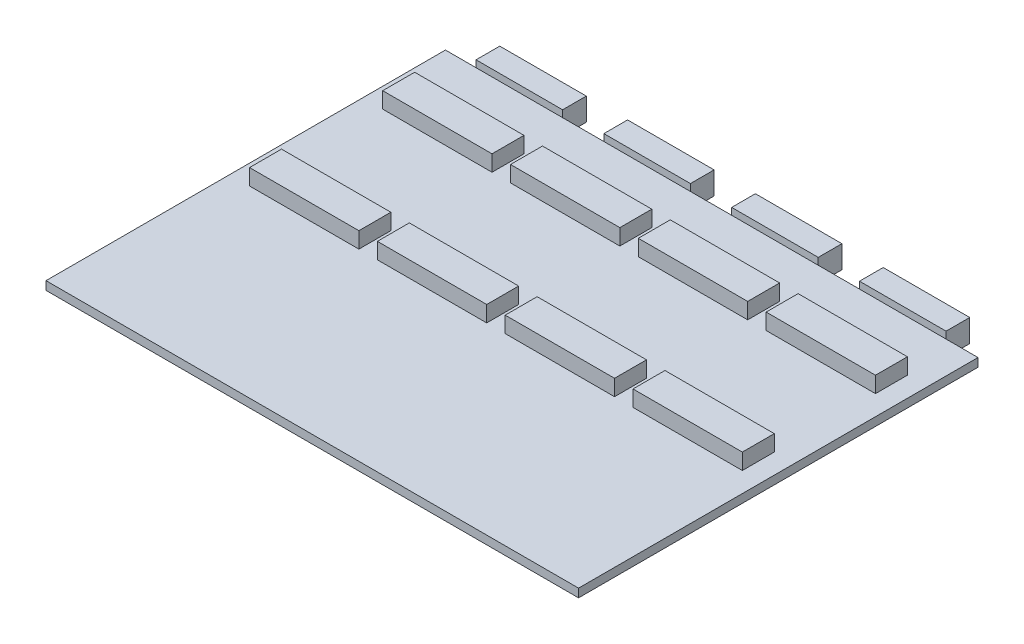
from build123d import *

# Parameters (mm, degrees)
SKETCH1_W            = 100
SKETCH1_H            = 75
BOSS_EXTRUDE1_DEPTH  = 1.5875
SKETCH2_W            = 20.53
SKETCH2_H            = 6
BOSS_EXTRUDE2_DEPTH  = 4.5875
LPATTERN1_COUNT      = 4
LPATTERN1_PITCH      = 24
LPATTERN1_COUNT_DIR2 = 2
LPATTERN1_PITCH_DIR2 = 25
SKETCH3_W            = 16.25
SKETCH3_H            = 4.25
BOSS_EXTRUDE3_DEPTH  = 4.45
LPATTERN2_COUNT      = 4
LPATTERN2_PITCH      = 24


with BuildPart() as part:
    # Sketch1 → Boss-Extrude1 (new body)
    with BuildSketch(Plane(origin=(0, 0, 0), x_dir=(1, 0, 0), z_dir=(0, 1, 0))):
        with Locations((50, 37.5)):
            Rectangle(SKETCH1_W, SKETCH1_H)
    extrude(amount=BOSS_EXTRUDE1_DEPTH)

    # Sketch2 → Boss-Extrude2 (add)
    with BuildSketch(Plane(origin=(0, 0, 0), x_dir=(1, 0, 0), z_dir=(0, 1, 0))):
        with Locations((13.985, 37.5)):
            Rectangle(SKETCH2_W, SKETCH2_H)
    boss_extrude2 = extrude(amount=BOSS_EXTRUDE2_DEPTH)

    # LPattern1: Boss-Extrude2 4 × 2
    with Locations(*[(i * LPATTERN1_PITCH, 0, -j * LPATTERN1_PITCH_DIR2) for i in range(LPATTERN1_COUNT) for j in range(LPATTERN1_COUNT_DIR2) if (i, j) != (0, 0)]):
        add(boss_extrude2)

    # Sketch3 → Boss-Extrude3 (add)
    with BuildSketch(Plane(origin=(0, 0, -75), x_dir=(-1, 0, 0), z_dir=(0, 0, -1))):
        with Locations((-13.875, 0.75)):
            Rectangle(SKETCH3_W, SKETCH3_H)
    boss_extrude3 = extrude(amount=BOSS_EXTRUDE3_DEPTH)

    # LPattern2: Boss-Extrude3 ×4
    with Locations(*[(i * LPATTERN2_PITCH, 0, 0) for i in range(1, LPATTERN2_COUNT)]):
        add(boss_extrude3)


solid = part.part
